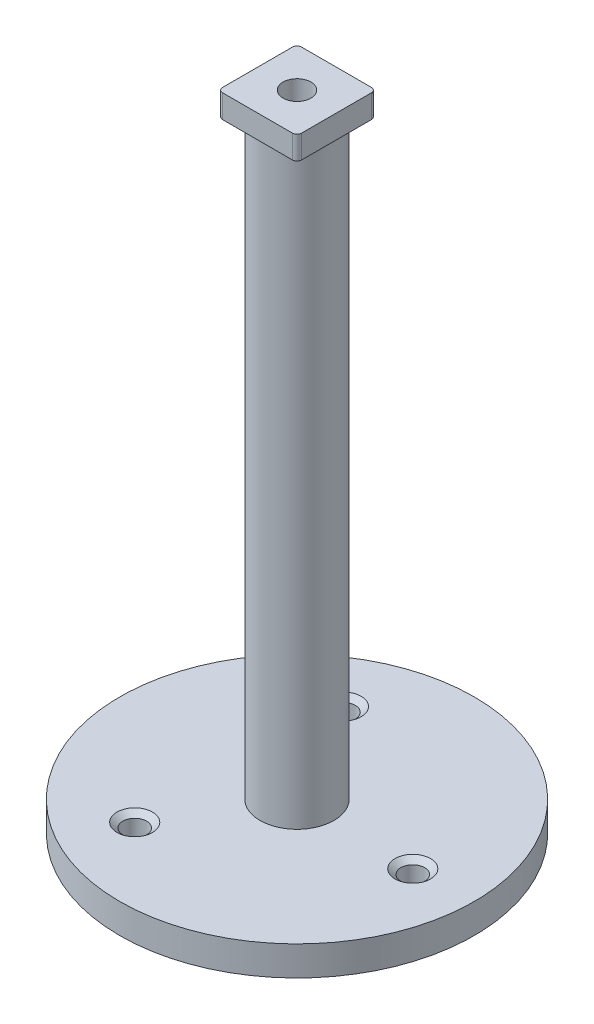
from build123d import *

# Parameters (mm, degrees)
SKETCH2_R                         = 7.14375
CUT_EXTRUDE1_DEPTH                = 120.65
SKETCH5_W                         = 17
SKETCH5_H                         = 17
BOSS_EXTRUDE3_DEPTH               = 5
SKETCH4_R                         = 3
CUT_EXTRUDE2_DEPTH                = 139.35
FILLET1_R                         = 1
FILLET2_R                         = 0.25
F_1_4_20_TAPPED_HOLE1_D           = 5.1054
F_1_4_20_TAPPED_HOLE1_CSINK_D     = 7.62
F_1_4_20_TAPPED_HOLE1_CSINK_ANGLE = 100


with BuildPart() as part:
    # Sketch1 → Revolve1 (revolve)
    with BuildSketch(Plane.XY):
        Polygon((0, 0), (38.1, 0), (38.1, 6.35), (7.9375, 6.35), (7.9375, 133.35), (0, 133.35), align=None)
    revolve(axis=Axis((0, 131.17698584, 0), (0, -1, 0)))

    # Sketch2 → Cut-Extrude1 (cut)
    with BuildSketch(Plane(origin=(0, 0, 0), x_dir=(1, 0, 0), z_dir=(0, 1, 0))):
        Circle(SKETCH2_R)
    extrude(amount=CUT_EXTRUDE1_DEPTH, mode=Mode.SUBTRACT)

    # Sketch5 → Boss-Extrude3 (add)
    with BuildSketch(Plane(origin=(0, 133.35, 0), x_dir=(1, 0, 0), z_dir=(0, 1, 0))):
        Rectangle(SKETCH5_W, SKETCH5_H)
    extrude(amount=BOSS_EXTRUDE3_DEPTH)

    # Sketch4 → Cut-Extrude2 (cut, through all)
    with BuildSketch(Plane(origin=(0, 138.35, 0), x_dir=(1, 0, 0), z_dir=(0, 1, 0))):
        Circle(SKETCH4_R)
    extrude(amount=-CUT_EXTRUDE2_DEPTH, mode=Mode.SUBTRACT)

    # Fillet1
    fillet1_edges = [part.edges().sort_by_distance(p)[0] for p in [
        (8.5, 135.85, 8.5),
        (8.5, 135.85, -8.5),
        (-8.5, 135.85, -8.5),
        (-8.5, 135.85, 8.5),
    ]]
    fillet(fillet1_edges, radius=FILLET1_R)

    # Fillet2
    fillet2_edges = [part.edges().sort_by_distance(p)[0] for p in [
        (-7.9375, 133.35, 0),
    ]]
    fillet(fillet2_edges, radius=FILLET2_R)

    # 1/4-20 Tapped Hole1 (through all)
    with Locations(Plane(origin=(0, 6.35, 0), x_dir=(1, 0, 0), z_dir=(0, 1, 0))):
        with Locations((-13.139703049, -21.737253823), (-12.255162495, 22.24794355), (25.394865544, -0.510689727)):
            CounterSinkHole(F_1_4_20_TAPPED_HOLE1_D / 2, F_1_4_20_TAPPED_HOLE1_CSINK_D / 2, counter_sink_angle=F_1_4_20_TAPPED_HOLE1_CSINK_ANGLE)


solid = part.part
